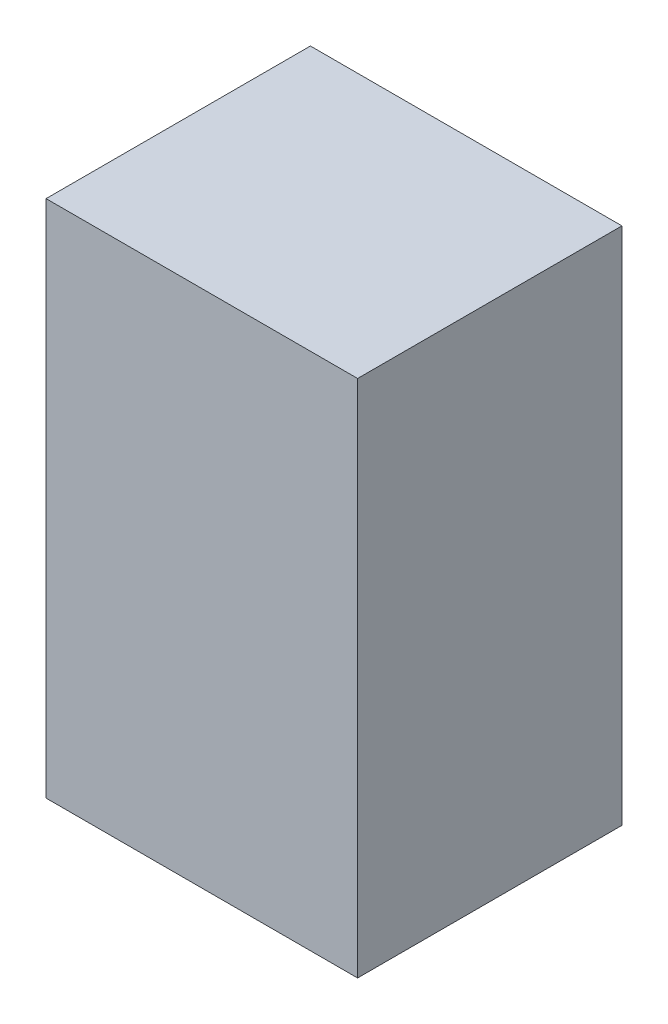
from build123d import *

# Parameters (mm, degrees)
SKETCH1_W           = 838.2
SKETCH1_H           = 711.2
BOSS_EXTRUDE1_DEPTH = 1397


with BuildPart() as part:
    # Sketch1 → Boss-Extrude1 (new body)
    with BuildSketch(Plane(origin=(0, 0, 0), x_dir=(1, 0, 0), z_dir=(0, 1, 0))):
        Rectangle(SKETCH1_W, SKETCH1_H)
    extrude(amount=BOSS_EXTRUDE1_DEPTH)


solid = part.part
